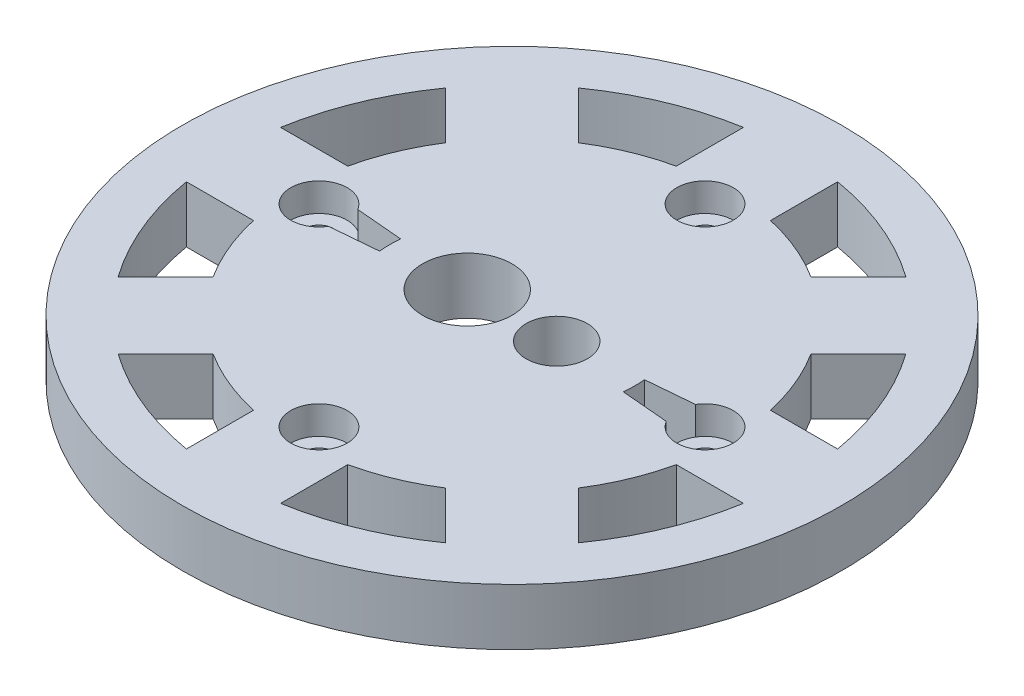
from build123d import *

# Parameters (mm, degrees)
SKETCH1_R           = 35
SKETCH1_R_2         = 3
SKETCH1_R_3         = 1.5
SKETCH1_R_4         = 4.75
SKETCH1_R_5         = 3.25
BOSS_EXTRUDE2_DEPTH = 6
CUT_EXTRUDE3_START  = 6
SKETCH1_6_R         = 3
CUT_EXTRUDE3_DEPTH  = 3
SKETCH1_7_R         = 3
SKETCH1_7_R_2       = 1.5
BOSS_EXTRUDE3_DEPTH = 3


with BuildPart() as part:
    # Sketch1 → Boss-Extrude2 (new body)
    with BuildSketch(Plane(origin=(0, 0, 0), x_dir=(1, 0, 0), z_dir=(0, 1, 0))):
        Circle(SKETCH1_R)
        with BuildLine():
            Line((-29.580398915, -5), (-22.449944321, -5))
            ThreePointArc((-22.449944321, -5), (-21.249229248, -8.801718944), (-19.410041772, -12.33897396))
            Line((-19.410041772, -12.33897396), (-24.452034569, -17.380966757))
            ThreePointArc((-24.452034569, -17.380966757), (-27.716385975, -11.480502971), (-29.580398915, -5))
        make_face(mode=Mode.SUBTRACT)
        with BuildLine():
            Line((-17.380966757, -24.452034569), (-12.33897396, -19.410041772))
            ThreePointArc((-12.33897396, -19.410041772), (-8.801718944, -21.249229248), (-5, -22.449944321))
            Line((-5, -22.449944321), (-5, -29.580398915))
            ThreePointArc((-5, -29.580398915), (-11.480502971, -27.716385975), (-17.380966757, -24.452034569))
        make_face(mode=Mode.SUBTRACT)
        with BuildLine():
            Line((5, -29.580398915), (5, -22.449944321))
            ThreePointArc((5, -22.449944321), (8.801718944, -21.249229248), (12.33897396, -19.410041772))
            Line((12.33897396, -19.410041772), (17.380966757, -24.452034569))
            ThreePointArc((17.380966757, -24.452034569), (11.480502971, -27.716385975), (5, -29.580398915))
        make_face(mode=Mode.SUBTRACT)
        with BuildLine():
            Line((24.452034569, -17.380966757), (19.410041772, -12.33897396))
            ThreePointArc((19.410041772, -12.33897396), (21.249229248, -8.801718944), (22.449944321, -5))
            Line((22.449944321, -5), (29.580398915, -5))
            ThreePointArc((29.580398915, -5), (27.716385975, -11.480502971), (24.452034569, -17.380966757))
        make_face(mode=Mode.SUBTRACT)
        with BuildLine():
            Line((29.580398915, 5), (22.449944321, 5))
            ThreePointArc((22.449944321, 5), (21.249229248, 8.801718944), (19.410041772, 12.33897396))
            Line((19.410041772, 12.33897396), (24.452034569, 17.380966757))
            ThreePointArc((24.452034569, 17.380966757), (27.716385975, 11.480502971), (29.580398915, 5))
        make_face(mode=Mode.SUBTRACT)
        with BuildLine():
            Line((17.380966757, 24.452034569), (12.33897396, 19.410041772))
            ThreePointArc((12.33897396, 19.410041772), (8.801718944, 21.249229248), (5, 22.449944321))
            Line((5, 22.449944321), (5, 29.580398915))
            ThreePointArc((5, 29.580398915), (11.480502971, 27.716385975), (17.380966757, 24.452034569))
        make_face(mode=Mode.SUBTRACT)
        with BuildLine():
            Line((-5, 29.580398915), (-5, 22.449944321))
            ThreePointArc((-5, 22.449944321), (-8.801718944, 21.249229248), (-12.33897396, 19.410041772))
            Line((-12.33897396, 19.410041772), (-17.380966757, 24.452034569))
            ThreePointArc((-17.380966757, 24.452034569), (-11.480502971, 27.716385975), (-5, 29.580398915))
        make_face(mode=Mode.SUBTRACT)
        with BuildLine():
            Line((-24.452034569, 17.380966757), (-19.410041772, 12.33897396))
            ThreePointArc((-19.410041772, 12.33897396), (-21.249229248, 8.801718944), (-22.449944321, 5))
            Line((-22.449944321, 5), (-29.580398915, 5))
            ThreePointArc((-29.580398915, 5), (-27.716385975, 11.480502971), (-24.452034569, 17.380966757))
        make_face(mode=Mode.SUBTRACT)
        with Locations((0, -20.5)):
            Circle(SKETCH1_R_2, mode=Mode.SUBTRACT)
        with Locations((-20.5, 0)):
            Circle(SKETCH1_R_3, mode=Mode.SUBTRACT)
        with BuildLine():
            Line((-12.951558266, -1.121221875), (-17.932926829, -1.552461058))
            ThreePointArc((-17.932926829, -1.552461058), (-17.5, 0), (-17.932926829, 1.552461058))
            Line((-17.932926829, 1.552461058), (-12.951558266, 1.121221875))
            ThreePointArc((-12.951558266, 1.121221875), (-13, 0), (-12.951558266, -1.121221875))
        make_face(mode=Mode.SUBTRACT)
        with Locations((-4.75, 0)):
            Circle(SKETCH1_R_4, mode=Mode.SUBTRACT)
        with Locations((4.75, 0)):
            Circle(SKETCH1_R_5, mode=Mode.SUBTRACT)
        with BuildLine():
            ThreePointArc((17.932926829, 1.552461058), (17.5, 0), (17.932926829, -1.552461058))
            Line((17.932926829, -1.552461058), (12.951558266, -1.121221875))
            ThreePointArc((12.951558266, -1.121221875), (13, 0), (12.951558266, 1.121221875))
            Line((12.951558266, 1.121221875), (17.932926829, 1.552461058))
        make_face(mode=Mode.SUBTRACT)
        with Locations((20.5, 0)):
            Circle(SKETCH1_R_3, mode=Mode.SUBTRACT)
        with Locations((0, 20.5)):
            Circle(SKETCH1_R_2, mode=Mode.SUBTRACT)
    extrude(amount=BOSS_EXTRUDE2_DEPTH)

    # Sketch1_6 → Cut-Extrude3 (cut)
    with BuildSketch(Plane(origin=(0, 0, 0), x_dir=(1, 0, 0), z_dir=(0, 1, 0)).offset(CUT_EXTRUDE3_START)):
        with Locations((20.5, 0)):
            Circle(SKETCH1_6_R)
        with Locations((-20.5, 0)):
            Circle(SKETCH1_6_R)
    extrude(amount=-CUT_EXTRUDE3_DEPTH, mode=Mode.SUBTRACT)

    # Sketch1_7 → Boss-Extrude3 (add)
    with BuildSketch(Plane(origin=(0, 0, 0), x_dir=(1, 0, 0), z_dir=(0, 1, 0))):
        with Locations((0, 20.5)):
            Circle(SKETCH1_7_R)
        with Locations((0, 20.5)):
            Circle(SKETCH1_7_R_2, mode=Mode.SUBTRACT)
        with Locations((0, -20.5)):
            Circle(SKETCH1_7_R)
        with Locations((0, -20.5)):
            Circle(SKETCH1_7_R_2, mode=Mode.SUBTRACT)
    extrude(amount=BOSS_EXTRUDE3_DEPTH)


solid = part.part
